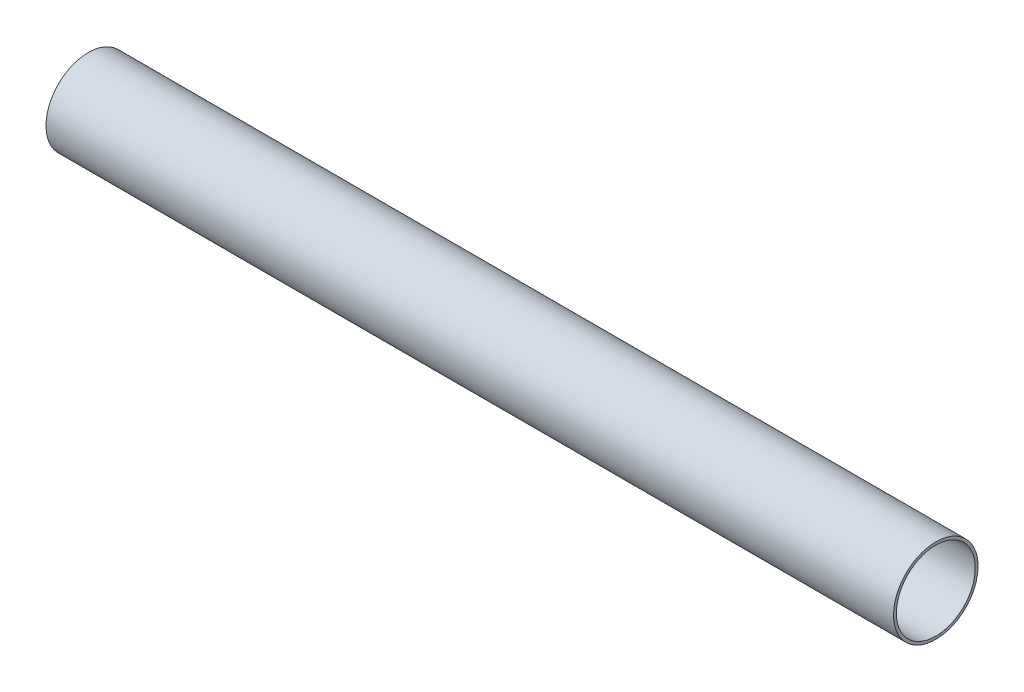
from build123d import *

# Parameters (mm, degrees)
SWEEP_THIN1_PROFILE_R   = 15
SWEEP_THIN1_PROFILE_R_2 = 14


with BuildPart() as part:
    # Sweep-Thin1: sweep along a curve in space
    with BuildLine() as sweep_thin1_path:
        Line((-34220.216064675, -17152.292793725, 39207.363931863), (-34520.976316453, -17152.292793725, 39207.363931863))
    # Sweep-Thin1 profile (on start of the path) → Sweep-Thin1 (sweep)
    with BuildSketch(Plane(origin=(-34220.216064675, -17152.292793725, 39207.363931863), x_dir=(0, 0, -1), z_dir=(-1, 0, 0))):
        Circle(SWEEP_THIN1_PROFILE_R)
        Circle(SWEEP_THIN1_PROFILE_R_2, mode=Mode.SUBTRACT)
    sweep(path=sweep_thin1_path.line)


solid = part.part
